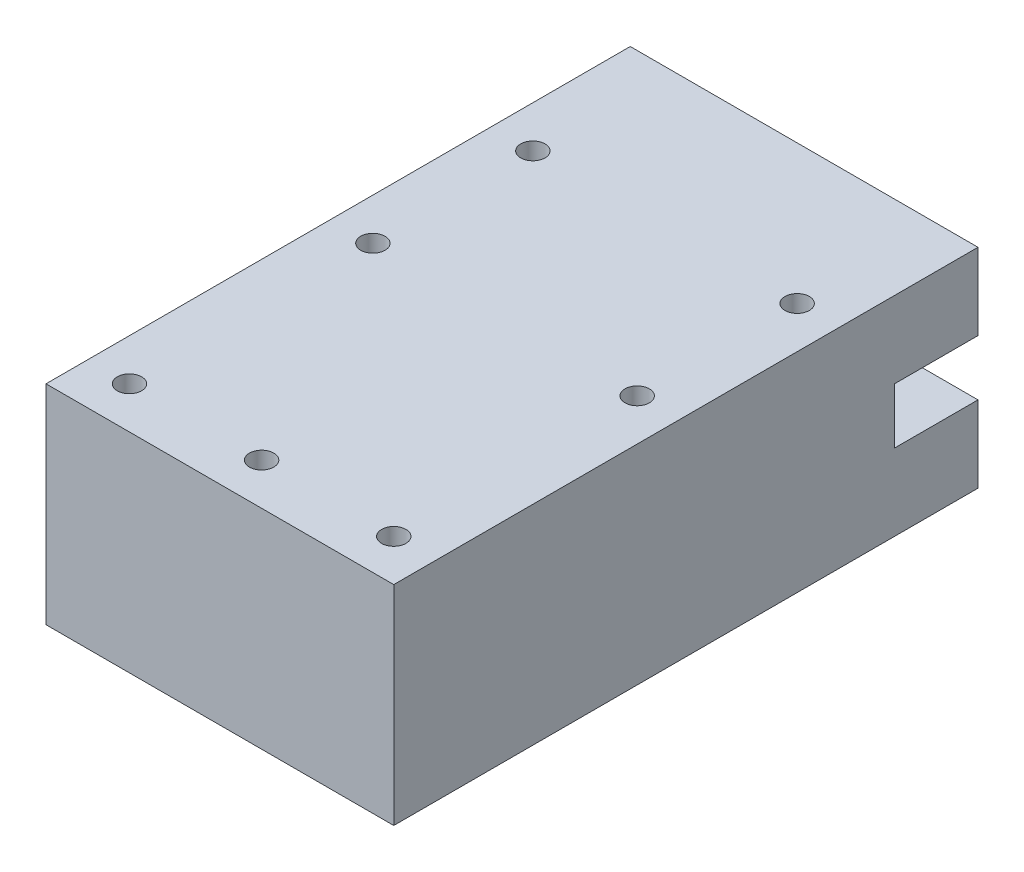
from build123d import *

# Parameters (mm, degrees)
SKETCH_1_W          = 50
SKETCH_1_H          = 30
EXTRUDE_1_DEPTH     = 84
SKETCH_2_W          = 26
SKETCH_2_H          = 14
CUT_EXTRUDE_1_DEPTH = 72
SKETCH_5_W          = 12
SKETCH_5_H          = 8
CUT_EXTRUDE_4_DEPTH = 13
SKETCH_6_W          = 12
SKETCH_6_H          = 8
CUT_EXTRUDE_5_DEPTH = 13
SKETCH_7_R          = 1.75
CUT_EXTRUDE_7_DEPTH = 31


with BuildPart() as part:
    # ｽｹｯﾁ1 → ﾎﾞｽ - 押し出し1 (new body)
    with BuildSketch(Plane.XY):
        Rectangle(SKETCH_1_W, SKETCH_1_H)
    extrude(amount=EXTRUDE_1_DEPTH)

    # ｽｹｯﾁ2 → ｶｯﾄ - 押し出し1 (cut)
    with BuildSketch(Plane(origin=(0, 0, 0), x_dir=(-1, 0, 0), z_dir=(0, 0, -1))):
        Rectangle(SKETCH_2_W, SKETCH_2_H)
    extrude(amount=-CUT_EXTRUDE_1_DEPTH, mode=Mode.SUBTRACT)

    # ｽｹｯﾁ5 → ｶｯﾄ - 押し出し4 (cut, through all)
    with BuildSketch(Plane.ZY.offset(-13)):
        with Locations((6, 0)):
            Rectangle(SKETCH_5_W, SKETCH_5_H)
    extrude(amount=-CUT_EXTRUDE_4_DEPTH, mode=Mode.SUBTRACT)

    # ｽｹｯﾁ6 → ｶｯﾄ - 押し出し5 (cut, through all)
    with BuildSketch(Plane(origin=(-13, 0, 0), x_dir=(0, 0, -1), z_dir=(1, 0, 0))):
        with Locations((-6, 0)):
            Rectangle(SKETCH_6_W, SKETCH_6_H)
    extrude(amount=-CUT_EXTRUDE_5_DEPTH, mode=Mode.SUBTRACT)

    # ｽｹｯﾁ7 → ｶｯﾄ - 押し出し7 (cut, through all)
    with BuildSketch(Plane(origin=(0, 15, 0), x_dir=(1, 0, 0), z_dir=(0, 1, 0))):
        with Locations((19, -20)):
            Circle(SKETCH_7_R)
        with Locations((19, -43)):
            Circle(SKETCH_7_R)
        with Locations((19, -78)):
            Circle(SKETCH_7_R)
        with Locations((0, -78)):
            Circle(SKETCH_7_R)
        with Locations((-19, -78)):
            Circle(SKETCH_7_R)
        with Locations((-19, -43)):
            Circle(SKETCH_7_R)
        with Locations((-19, -20)):
            Circle(SKETCH_7_R)
    extrude(amount=-CUT_EXTRUDE_7_DEPTH, mode=Mode.SUBTRACT)


solid = part.part
